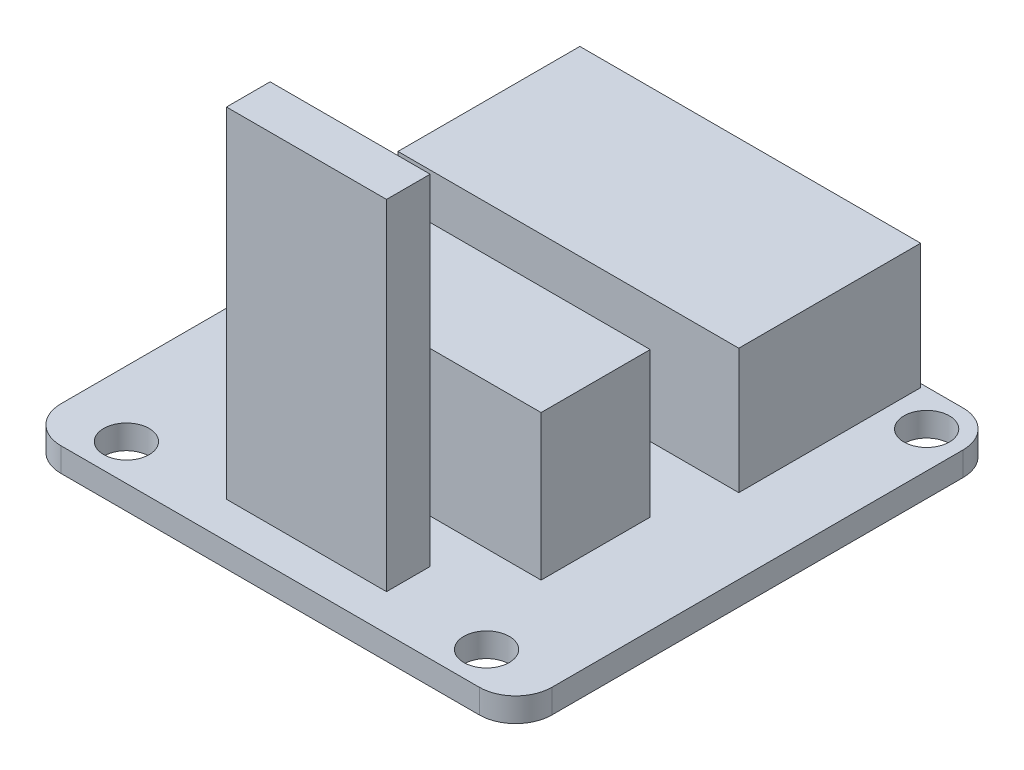
from build123d import *

# Parameters (mm, degrees)
SKETCH1_R           = 1.5875
BOSS_EXTRUDE1_DEPTH = 1.6764
SKETCH1_3_W         = 23.7998
SKETCH1_3_H         = 12.7
BOSS_EXTRUDE2_DEPTH = 10.414
SKETCH1_4_W         = 20.574
SKETCH1_4_H         = 7.62
BOSS_EXTRUDE3_DEPTH = 11.811
SKETCH1_5_W         = 11.176
SKETCH1_5_H         = 3.048
BOSS_EXTRUDE4_DEPTH = 25.4


with BuildPart() as part:
    # Sketch1 → Boss-Extrude1 (new body)
    with BuildSketch(Plane(origin=(0, 0, 0), x_dir=(1, 0, 0), z_dir=(0, 1, 0))):
        with BuildLine():
            ThreePointArc((-17.145, -14.351), (-16.401051224, -16.147051224), (-14.605, -16.891))
            Line((-14.605, -16.891), (14.605, -16.891))
            ThreePointArc((14.605, -16.891), (16.401051224, -16.147051224), (17.145, -14.351))
            Line((17.145, -14.351), (17.145, 14.351))
            ThreePointArc((17.145, 14.351), (16.401051224, 16.147051224), (14.605, 16.891))
            Line((14.605, 16.891), (-14.605, 16.891))
            ThreePointArc((-14.605, 16.891), (-16.401051224, 16.147051224), (-17.145, 14.351))
            Line((-17.145, 14.351), (-17.145, -14.351))
        make_face()
        with Locations((-12.573, -14.351)):
            Circle(SKETCH1_R, mode=Mode.SUBTRACT)
        with Locations((12.573, -14.351)):
            Circle(SKETCH1_R, mode=Mode.SUBTRACT)
        with Locations((-14.605, 14.351)):
            Circle(SKETCH1_R, mode=Mode.SUBTRACT)
        with Locations((14.605, 14.351)):
            Circle(SKETCH1_R, mode=Mode.SUBTRACT)
    extrude(amount=BOSS_EXTRUDE1_DEPTH)

    # Sketch1_3 → Boss-Extrude2 (add)
    with BuildSketch(Plane(origin=(0, 0, 0), x_dir=(1, 0, 0), z_dir=(0, 1, 0))):
        with Locations((0, 10.287)):
            Rectangle(SKETCH1_3_W, SKETCH1_3_H)
    extrude(amount=BOSS_EXTRUDE2_DEPTH)

    # Sketch1_4 → Boss-Extrude3 (add)
    with BuildSketch(Plane(origin=(0, 0, 0), x_dir=(1, 0, 0), z_dir=(0, 1, 0))):
        with Locations((0, -4.445)):
            Rectangle(SKETCH1_4_W, SKETCH1_4_H)
    extrude(amount=BOSS_EXTRUDE3_DEPTH)

    # Sketch1_5 → Boss-Extrude4 (add)
    with BuildSketch(Plane(origin=(0, 0, 0), x_dir=(1, 0, 0), z_dir=(0, 1, 0))):
        with Locations((0, -12.827)):
            Rectangle(SKETCH1_5_W, SKETCH1_5_H)
    extrude(amount=BOSS_EXTRUDE4_DEPTH)


solid = part.part
